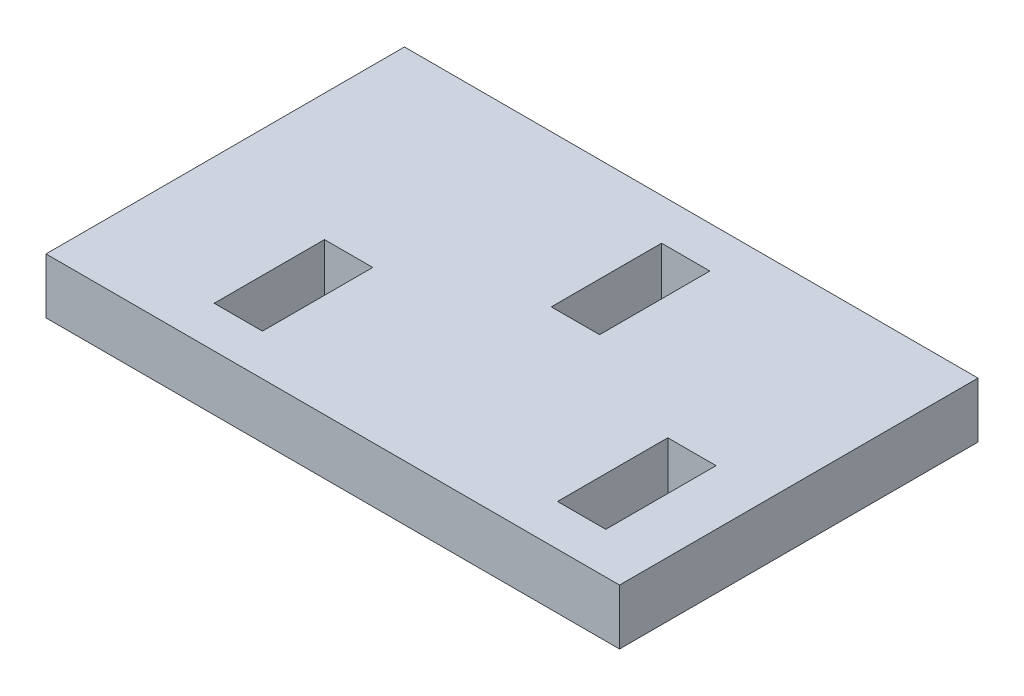
from build123d import *

# Parameters (mm, degrees)
SKETCH1_W           = 52.832
SKETCH1_H           = 33.02
BOSS_EXTRUDE1_DEPTH = 5.1054
SKETCH2_W           = 4.445
SKETCH2_H           = 10.16
CUT_EXTRUDE1_DEPTH  = 6.1054


with BuildPart() as part:
    # Sketch1 → Boss-Extrude1 (new body)
    with BuildSketch(Plane(origin=(0, 0, 0), x_dir=(1, 0, 0), z_dir=(0, 1, 0))):
        Rectangle(SKETCH1_W, SKETCH1_H)
    extrude(amount=BOSS_EXTRUDE1_DEPTH)

    # Sketch2 → Cut-Extrude1 (cut, through all)
    with BuildSketch(Plane(origin=(0, 5.1054, 0), x_dir=(1, 0, 0), z_dir=(0, 1, 0))):
        with Locations((19.1135, -7.62)):
            Rectangle(SKETCH2_W, SKETCH2_H)
        with Locations((3.302, 7.62)):
            Rectangle(SKETCH2_W, SKETCH2_H)
        with Locations((-12.5095, -7.62)):
            Rectangle(SKETCH2_W, SKETCH2_H)
    extrude(amount=-CUT_EXTRUDE1_DEPTH, mode=Mode.SUBTRACT)


solid = part.part
